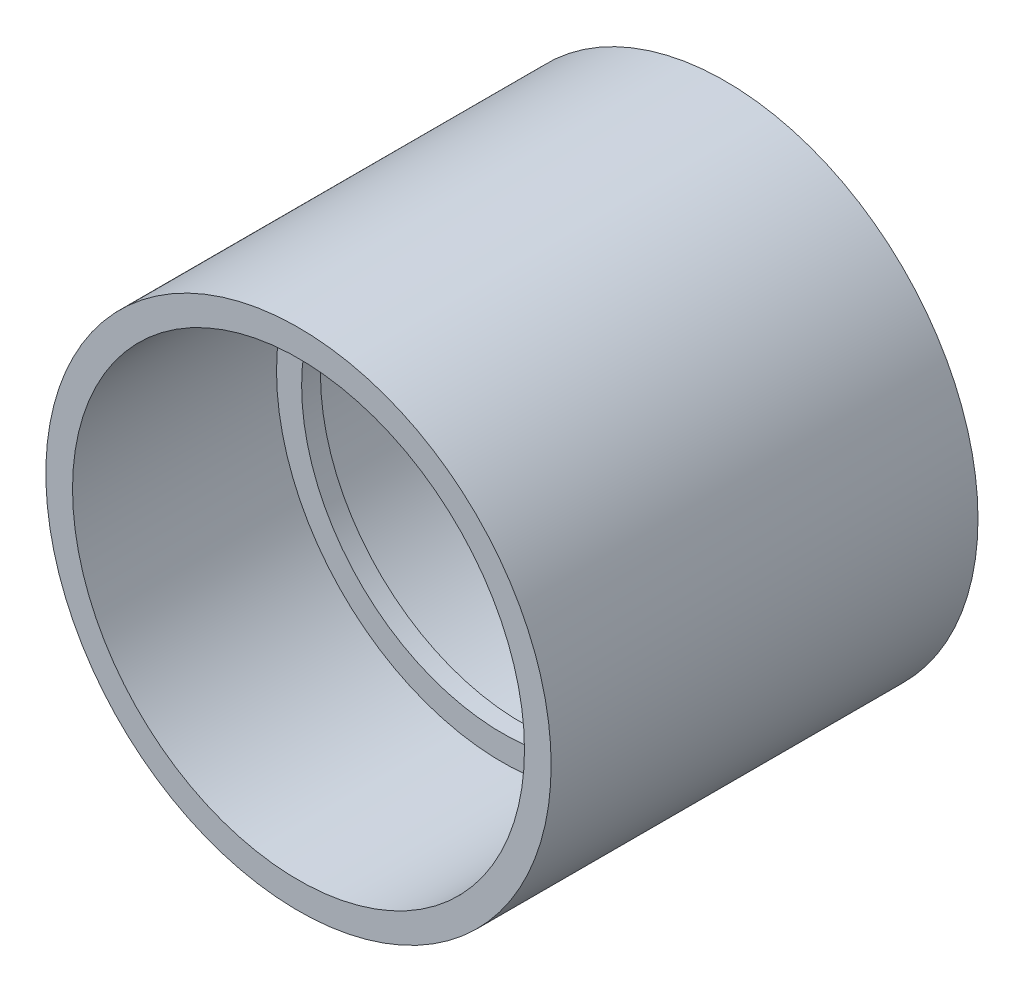
from build123d import *


with BuildPart() as part:
    # Sketch2 → Revolve1 (revolve)
    with BuildSketch(Plane(origin=(0, 0, 0), x_dir=(0, 0, -1), z_dir=(1, 0, 0)), mode=Mode.PRIVATE) as revolve1_sk:
        Polygon((-53.975, 63.896875), (53.975, 63.896875), (53.975, 57.15), (2.38125, 57.15), (2.38125, 50.8), (-2.38125, 50.8), (-2.38125, 57.15), (-53.975, 57.15), align=None)
    revolve(revolve1_sk.sketch.rotate(Axis((0, 0, 62.594581749), (0, 0, -1)), 90), axis=Axis((0, 0, 62.594581749), (0, 0, -1)))  # turned: the seam where the file's is


solid = part.part
